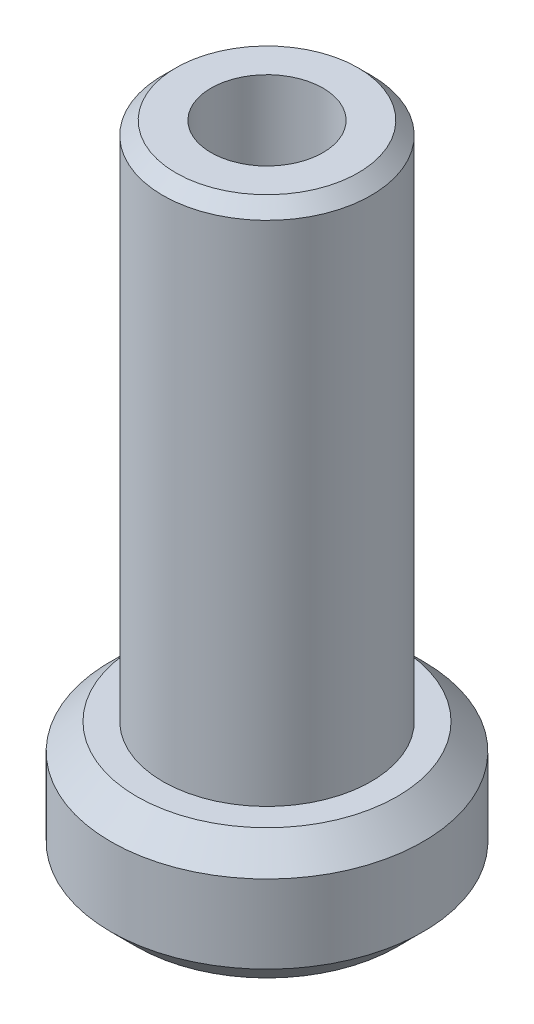
from build123d import *

# Parameters (mm, degrees)
STIRNSENKUNG_F_R_M4_ZYLINDERSCHRAUBE_MIT_D           = 4.3
STIRNSENKUNG_F_R_M4_ZYLINDERSCHRAUBE_MIT_CBORE_D     = 8
STIRNSENKUNG_F_R_M4_ZYLINDERSCHRAUBE_MIT_CBORE_DEPTH = 2
FASE1_SIZE                                           = 1
FASE2_SIZE                                           = 0.5


with BuildPart() as part:
    # Skizze1 → Rotation1 (revolve)
    with BuildSketch(Plane.XY):
        Polygon((0, 0), (0, 25), (-4, 25), (-4, 5), (-6, 5), (-6, 0), align=None)
    revolve(axis=Axis((0, 0, 0), (0, -1, 0)))

    # Stirnsenkung für M4 Zylinderschraube mit Innensechskant1 (through all)
    with Locations(Plane(origin=(0, 0, 0), x_dir=(-1, 0, 0), z_dir=(0, -1, 0))):
        with Locations((0, 0)):
            CounterBoreHole(STIRNSENKUNG_F_R_M4_ZYLINDERSCHRAUBE_MIT_D / 2, STIRNSENKUNG_F_R_M4_ZYLINDERSCHRAUBE_MIT_CBORE_D / 2, STIRNSENKUNG_F_R_M4_ZYLINDERSCHRAUBE_MIT_CBORE_DEPTH)

    # Fase1
    fase1_edges = [part.edges().sort_by_distance(p)[0] for p in [
        (6, 0, 0),
        (6, 5, 0),
    ]]
    chamfer(fase1_edges, length=FASE1_SIZE)

    # Fase2
    fase2_edges = [part.edges().sort_by_distance(p)[0] for p in [
        (4, 25, 0),
    ]]
    chamfer(fase2_edges, length=FASE2_SIZE)


solid = part.part
